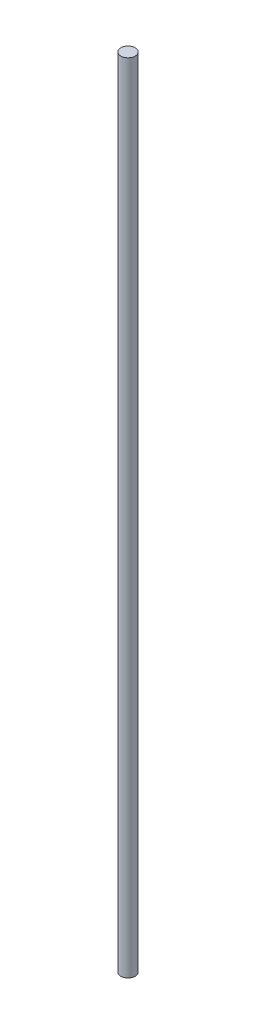
from build123d import *

# Parameters (mm, degrees)
SKETCH1_R           = 3.175
BOSS_EXTRUDE1_DEPTH = 350


with BuildPart() as part:
    # Sketch1 → Boss-Extrude1 (new body)
    with BuildSketch(Plane(origin=(0, 0, 0), x_dir=(1, 0, 0), z_dir=(0, 1, 0))):
        Circle(SKETCH1_R)
    extrude(amount=BOSS_EXTRUDE1_DEPTH)


solid = part.part
